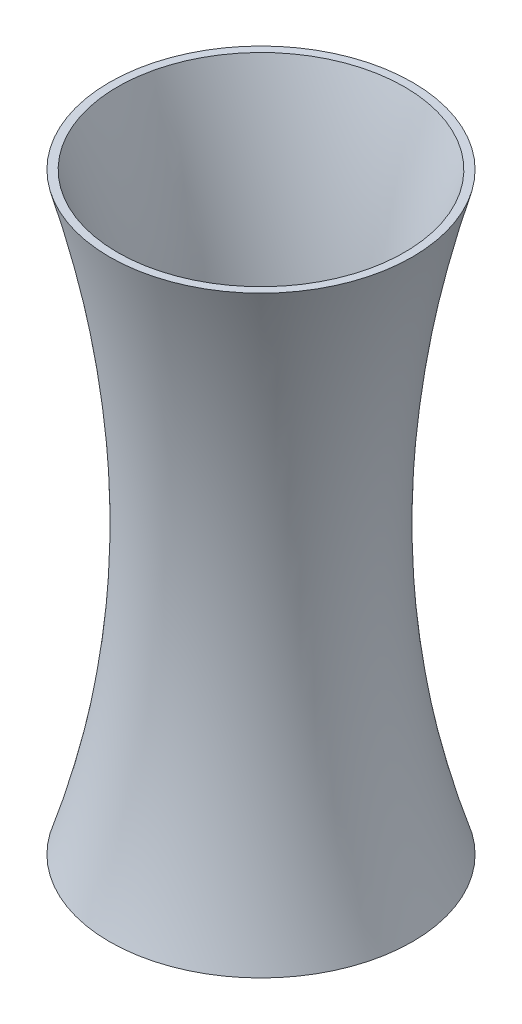
from build123d import *


with BuildPart() as part:
    # Sketch1 → Revolve2 (revolve)
    with BuildSketch(Plane.XY):
        with BuildLine():
            add(Edge.make_bspline(
                [(-45.96, 190), (-17.385, 101.1), (-45.96, 0)],
                knots=[0, 0, 0, 1, 1, 1], degree=2))
            Line((-45.96, 190), (-48.5, 190))
            add(Edge.make_bspline(
                [(-48.5, 190), (-19.925, 88.9), (-48.5, 0)],
                knots=[0, 0, 0, 1, 1, 1], degree=2))
            Line((-48.5, 0), (-45.96, 0))
        make_face()
    revolve(axis=Axis((0, 0, 0), (0, 1, 0)))


solid = part.part
